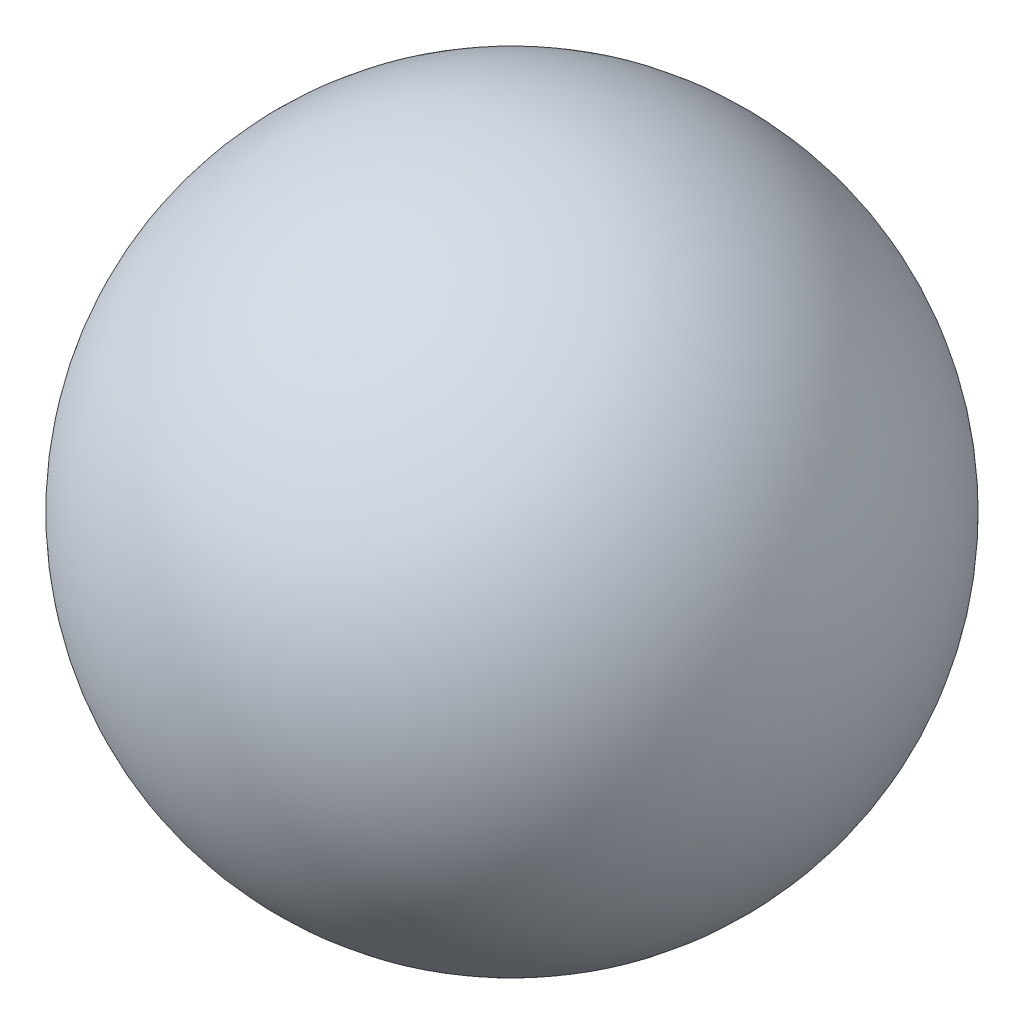
from build123d import *


with BuildPart() as part:
    # Sketch1 → Revolve1 (revolve)
    with BuildSketch(Plane.XY):
        with BuildLine():
            Line((0, 67.989363921), (0, 10.693691345))
            ThreePointArc((0, 10.693691345), (28.647836288, 39.341527633), (0, 67.989363921))
        make_face()
    revolve(axis=Axis((0, 0, 0), (0, 1, 0)))


solid = part.part
